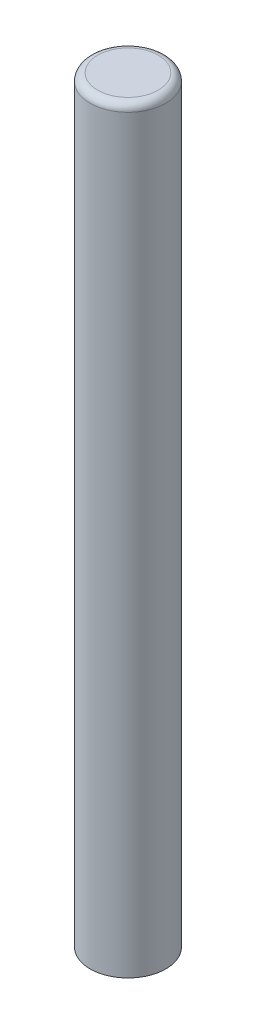
from build123d import *

# Parameters (mm, degrees)
SKETCH1_R           = 5
BOSS_EXTRUDE1_DEPTH = 100
FILLET1_R           = 1


with BuildPart() as part:
    # Sketch1 → Boss-Extrude1 (new body)
    with BuildSketch(Plane(origin=(0, 0, 0), x_dir=(1, 0, 0), z_dir=(0, 1, 0))):
        Circle(SKETCH1_R)
    extrude(amount=BOSS_EXTRUDE1_DEPTH)

    # Fillet1
    fillet1_edges = [part.edges().sort_by_distance(p)[0] for p in [
        (-5, 100, 0),
    ]]
    fillet(fillet1_edges, radius=FILLET1_R)


solid = part.part
